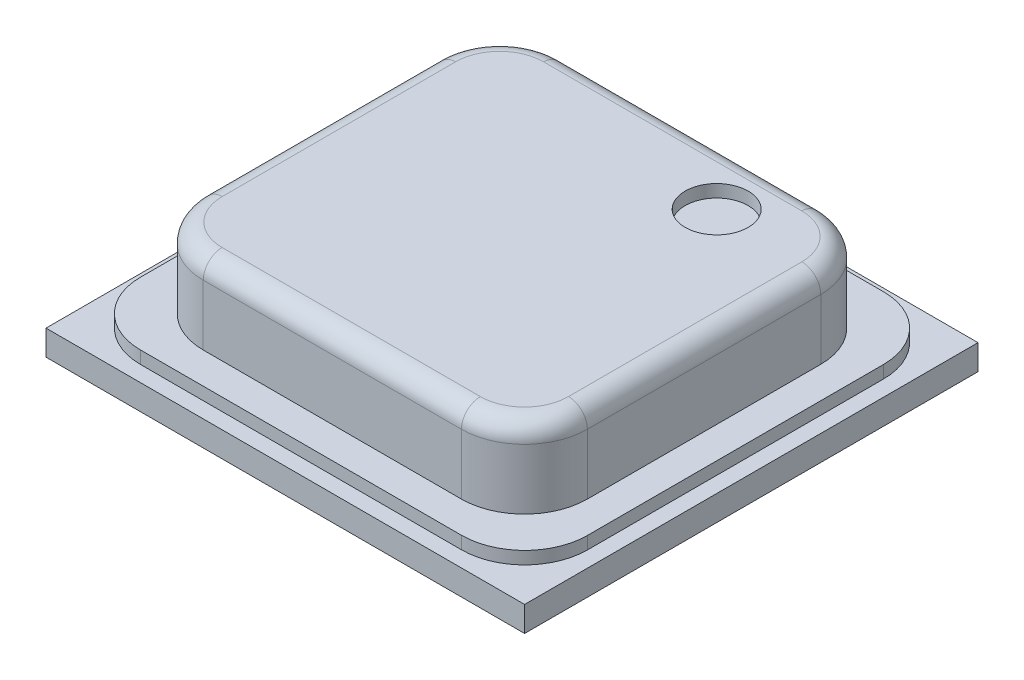
from build123d import *

# Parameters (mm, degrees)
SKETCH1_W           = 3.8
SKETCH1_H           = 3.6
BOSS_EXTRUDE1_DEPTH = 0.2
SKETCH3_W           = 3.55
SKETCH3_H           = 3.35
BOSS_EXTRUDE2_DEPTH = 0.1
FILLET1_R           = 0.5
SKETCH4_W           = 3.05
SKETCH4_H           = 2.853
BOSS_EXTRUDE3_DEPTH = 0.63
FILLET2_R           = 0.5
FILLET5_R           = 0.15
SKETCH5_R           = 0.25
CUT_EXTRUDE1_DEPTH  = 0.1


with BuildPart() as part:
    # Sketch1 → Boss-Extrude1 (new body)
    with BuildSketch(Plane(origin=(0, 0, 0), x_dir=(1, 0, 0), z_dir=(0, 1, 0))):
        Rectangle(SKETCH1_W, SKETCH1_H)
    extrude(amount=BOSS_EXTRUDE1_DEPTH)

    # Sketch3 → Boss-Extrude2 (add)
    with BuildSketch(Plane(origin=(0, 0.2, 0), x_dir=(1, 0, 0), z_dir=(0, 1, 0))):
        Rectangle(SKETCH3_W, SKETCH3_H)
    extrude(amount=BOSS_EXTRUDE2_DEPTH)

    # Fillet1
    fillet1_edges = [part.edges().sort_by_distance(p)[0] for p in [
        (1.775, 0.25, 1.675),
        (1.775, 0.25, -1.675),
        (-1.775, 0.25, -1.675),
        (-1.775, 0.25, 1.675),
    ]]
    fillet(fillet1_edges, radius=FILLET1_R)

    # Sketch4 → Boss-Extrude3 (add)
    with BuildSketch(Plane(origin=(0, 0.3, 0), x_dir=(1, 0, 0), z_dir=(0, 1, 0))):
        Rectangle(SKETCH4_W, SKETCH4_H)
    extrude(amount=BOSS_EXTRUDE3_DEPTH)

    # Fillet2
    fillet2_edges = [part.edges().sort_by_distance(p)[0] for p in [
        (1.525, 0.615, 1.4265),
        (1.525, 0.615, -1.4265),
        (-1.525, 0.615, -1.4265),
        (-1.525, 0.615, 1.4265),
    ]]
    fillet(fillet2_edges, radius=FILLET2_R)

    # Fillet5
    fillet5_edges = [part.edges().sort_by_distance(p)[0] for p in [
        (0, 0.93, -1.4265),
        (1.525, 0.93, 0),
        (-1.525, 0.93, 0),
        (0, 0.93, 1.4265),
        (-1.378553391, 0.93, 1.280053391),
        (-1.378553391, 0.93, -1.280053391),
        (1.378553391, 0.93, 1.280053391),
        (1.378553391, 0.93, -1.280053391),
    ]]
    fillet(fillet5_edges, radius=FILLET5_R)

    # Sketch5 → Cut-Extrude1 (cut)
    with BuildSketch(Plane(origin=(0, 0.93, 0), x_dir=(1, 0, 0), z_dir=(0, 1, 0))):
        with Locations((0.675, 0.95)):
            Circle(SKETCH5_R)
    extrude(amount=-CUT_EXTRUDE1_DEPTH, mode=Mode.SUBTRACT)


solid = part.part
